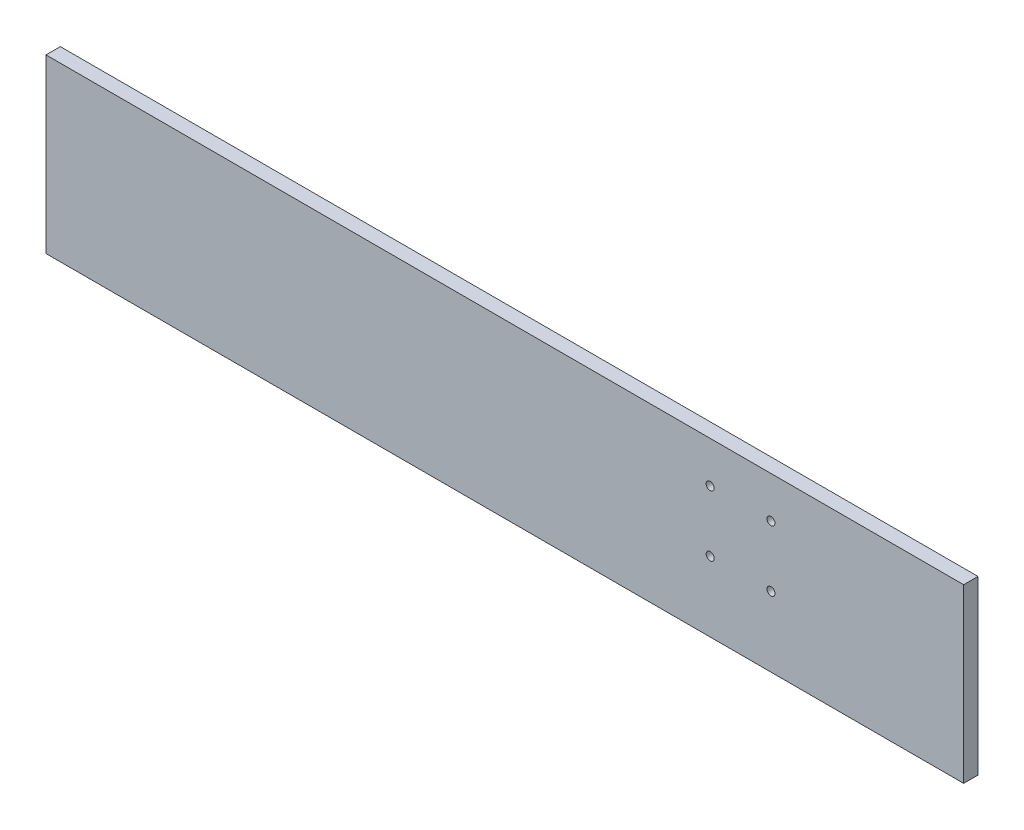
from build123d import *

# Parameters (mm, degrees)
SKETCH1_W           = 406.4
SKETCH1_H           = 76.2
BOSS_EXTRUDE1_DEPTH = 6.35
SKETCH2_R           = 1.778
CUT_EXTRUDE1_DEPTH  = 10.16


with BuildPart() as part:
    # Sketch1 → Boss-Extrude1 (new body)
    with BuildSketch(Plane.XY):
        with Locations((203.2, 38.1)):
            Rectangle(SKETCH1_W, SKETCH1_H)
    extrude(amount=BOSS_EXTRUDE1_DEPTH)

    # Sketch2 → Cut-Extrude1 (cut)
    with BuildSketch(Plane.XY.offset(6.35)):
        with Locations((294.112385825, 57.937084818)):
            Circle(SKETCH2_R)
        with Locations((321.053144818, 57.959554175)):
            Circle(SKETCH2_R)
        with Locations((321.075614175, 31.018795182)):
            Circle(SKETCH2_R)
        with Locations((294.134855182, 30.996325825)):
            Circle(SKETCH2_R)
    extrude(amount=-CUT_EXTRUDE1_DEPTH, mode=Mode.SUBTRACT)


solid = part.part
